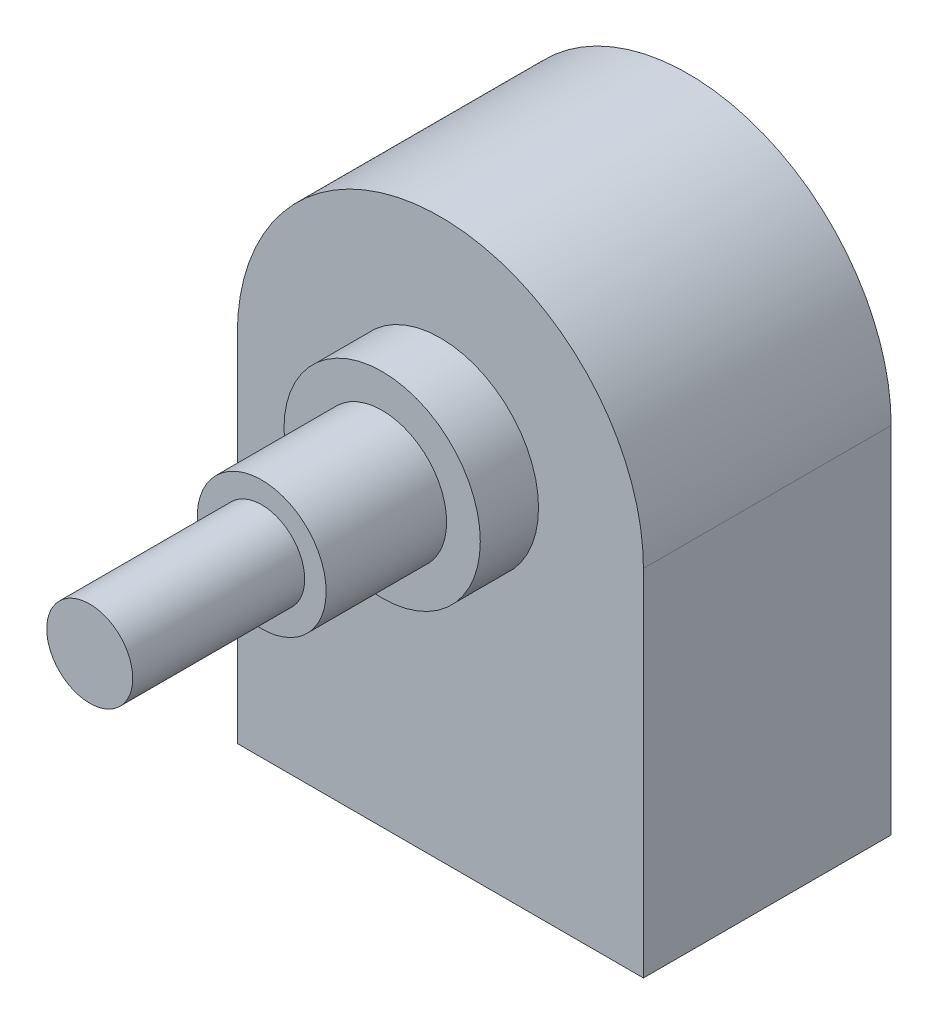
from build123d import *

# Parameters (mm, degrees)
BOSS_EXTRU_1_DEPTH      = 18.3
ESQUISSE2_R             = 7.25
BOSS_EXTRU_2_DEPTH      = 4.3
ESQUISSE3_R             = 4.7625
BOSS_EXTRU_3_DEPTH      = 8.9
ESQUISSE4_R             = 3.175
BOSS_EXTRU_4_DEPTH      = 12.7
ESQUISSE5_W             = 14.36
ESQUISSE5_H             = 7.1
ENL_V_MAT_EXTRU_2_DEPTH = 6
ESQUISSE6_W             = 0.64
ESQUISSE6_H             = 0.64
BOSS_EXTRU_5_DEPTH      = 8


with BuildPart() as part:
    # Esquisse1 → Boss.-Extru.1 (new body)
    with BuildSketch(Plane.XY):
        with BuildLine():
            Line((-15, -13.1), (15, -13.1))
            Line((15, -13.1), (15, 13.1))
            ThreePointArc((15, 13.1), (0, 28.1), (-15, 13.1))
            Line((-15, 13.1), (-15, -13.1))
        make_face()
    extrude(amount=BOSS_EXTRU_1_DEPTH)

    # Esquisse2 → Boss.-Extru.2 (add)
    with BuildSketch(Plane.XY.offset(18.3)):
        with Locations((0, 13.1)):
            Circle(ESQUISSE2_R)
    extrude(amount=BOSS_EXTRU_2_DEPTH)

    # Esquisse3 → Boss.-Extru.3 (add)
    with BuildSketch(Plane.XY.offset(22.6)):
        with Locations((0, 13.1)):
            Circle(ESQUISSE3_R)
    extrude(amount=BOSS_EXTRU_3_DEPTH)

    # Esquisse4 → Boss.-Extru.4 (add)
    with BuildSketch(Plane.XY.offset(31.5)):
        with Locations((0, 13.1)):
            Circle(ESQUISSE4_R)
    extrude(amount=BOSS_EXTRU_4_DEPTH)

    # Esquisse5 → Enlèv. mat.-Extru.2 (cut)
    with BuildSketch(Plane.XZ.offset(13.1)):
        with Locations((0, 11.75)):
            Rectangle(ESQUISSE5_W, ESQUISSE5_H)
    extrude(amount=-ENL_V_MAT_EXTRU_2_DEPTH, mode=Mode.SUBTRACT)

    # Esquisse6 → Boss.-Extru.5 (add)
    with BuildSketch(Plane.XZ.offset(7.1)):
        with Locations((-5, 12.457086597)):
            Rectangle(ESQUISSE6_W, ESQUISSE6_H)
        with Locations((-2.5, 12.457086597)):
            Rectangle(ESQUISSE6_W, ESQUISSE6_H)
        with Locations((0, 12.457086597)):
            Rectangle(ESQUISSE6_W, ESQUISSE6_H)
        with Locations((2.5, 12.457086597)):
            Rectangle(ESQUISSE6_W, ESQUISSE6_H)
        with Locations((5, 12.457086597)):
            Rectangle(ESQUISSE6_W, ESQUISSE6_H)
    extrude(amount=BOSS_EXTRU_5_DEPTH)


solid = part.part
